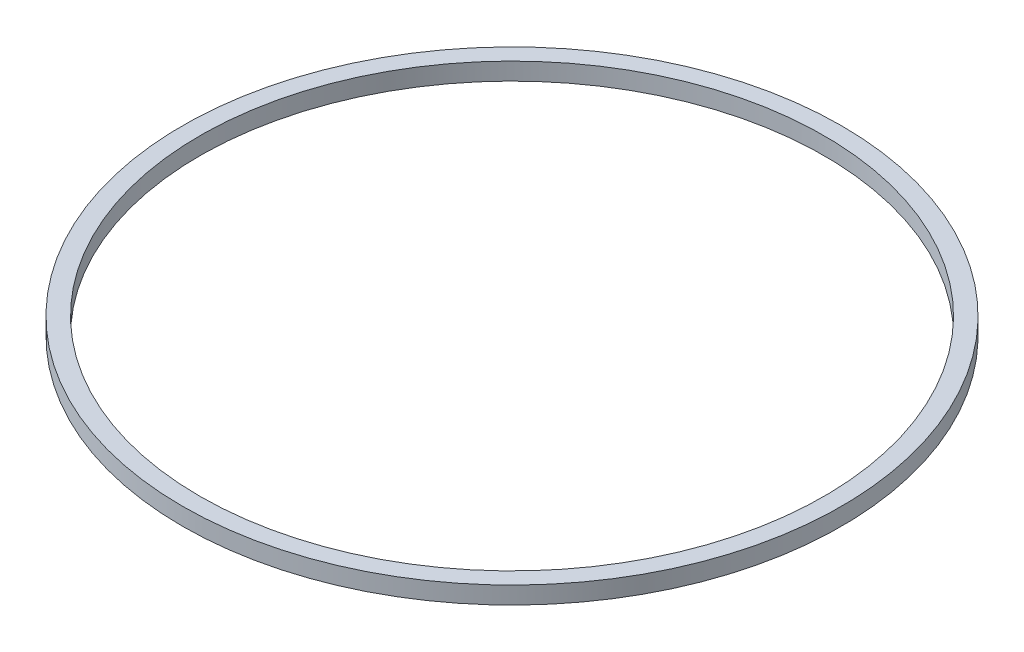
from build123d import *

# Parameters (mm, degrees)
SKETCH1_R           = 57
SKETCH1_R_2         = 54
BOSS_EXTRUDE1_DEPTH = 3


with BuildPart() as part:
    # Sketch1 → Boss-Extrude1 (new body)
    with BuildSketch(Plane(origin=(0, 0, 0), x_dir=(1, 0, 0), z_dir=(0, 1, 0))):
        Circle(SKETCH1_R)
        Circle(SKETCH1_R_2, mode=Mode.SUBTRACT)
    extrude(amount=BOSS_EXTRUDE1_DEPTH)


solid = part.part
